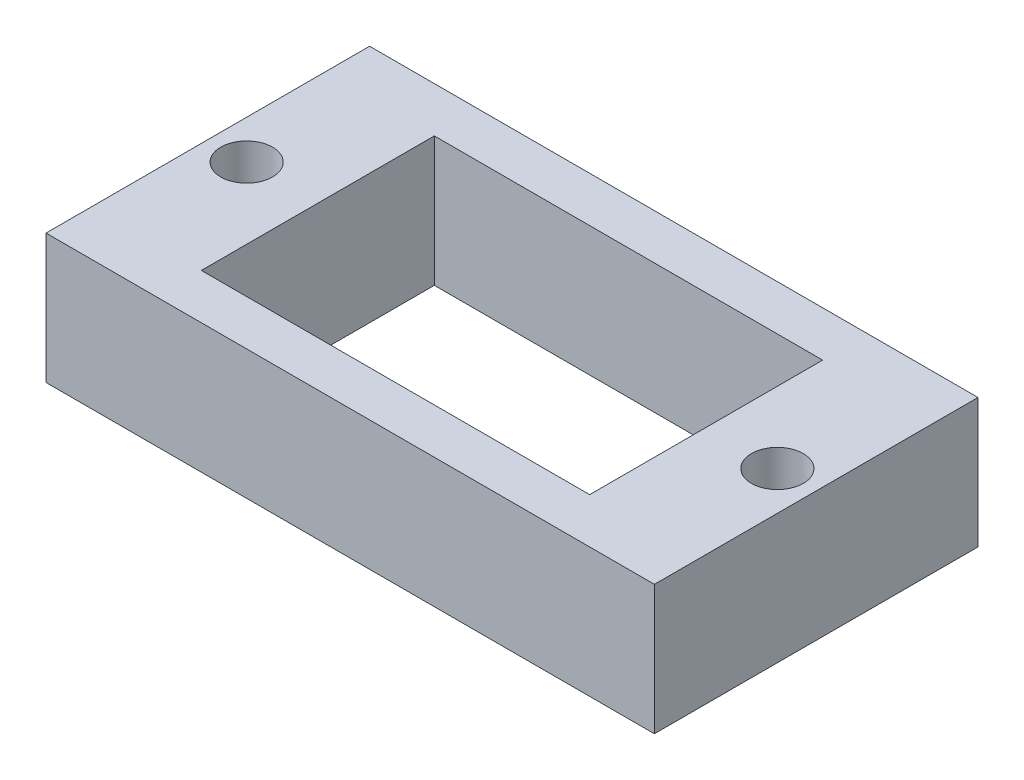
from build123d import *

# Parameters (mm, degrees)
SKETCH1_W           = 47
SKETCH1_H           = 25
BOSS_EXTRUDE1_DEPTH = 10
SKETCH2_R           = 2
CUT_EXTRUDE1_DEPTH  = 8
SKETCH5_W           = 30
SKETCH5_H           = 18
CUT_EXTRUDE2_DEPTH  = 10


with BuildPart() as part:
    # Sketch1 → Boss-Extrude1 (new body)
    with BuildSketch(Plane(origin=(0, 0, 0), x_dir=(1, 0, 0), z_dir=(0, 1, 0))):
        with Locations((23.5, 12.5)):
            Rectangle(SKETCH1_W, SKETCH1_H)
    extrude(amount=BOSS_EXTRUDE1_DEPTH)

    # Sketch2 → Cut-Extrude1 (cut)
    with BuildSketch(Plane(origin=(0, 10, 0), x_dir=(1, 0, 0), z_dir=(0, 1, 0))):
        with Locations((3, 12.5)):
            Circle(SKETCH2_R)
        with Locations((44, 12.5)):
            Circle(SKETCH2_R)
    extrude(amount=-CUT_EXTRUDE1_DEPTH, mode=Mode.SUBTRACT)

    # Sketch5 → Cut-Extrude2 (cut)
    with BuildSketch(Plane(origin=(0, 10, 0), x_dir=(1, 0, 0), z_dir=(0, 1, 0))):
        with Locations((23.5, 12.5)):
            Rectangle(SKETCH5_W, SKETCH5_H)
    extrude(amount=-CUT_EXTRUDE2_DEPTH, mode=Mode.SUBTRACT)


solid = part.part
